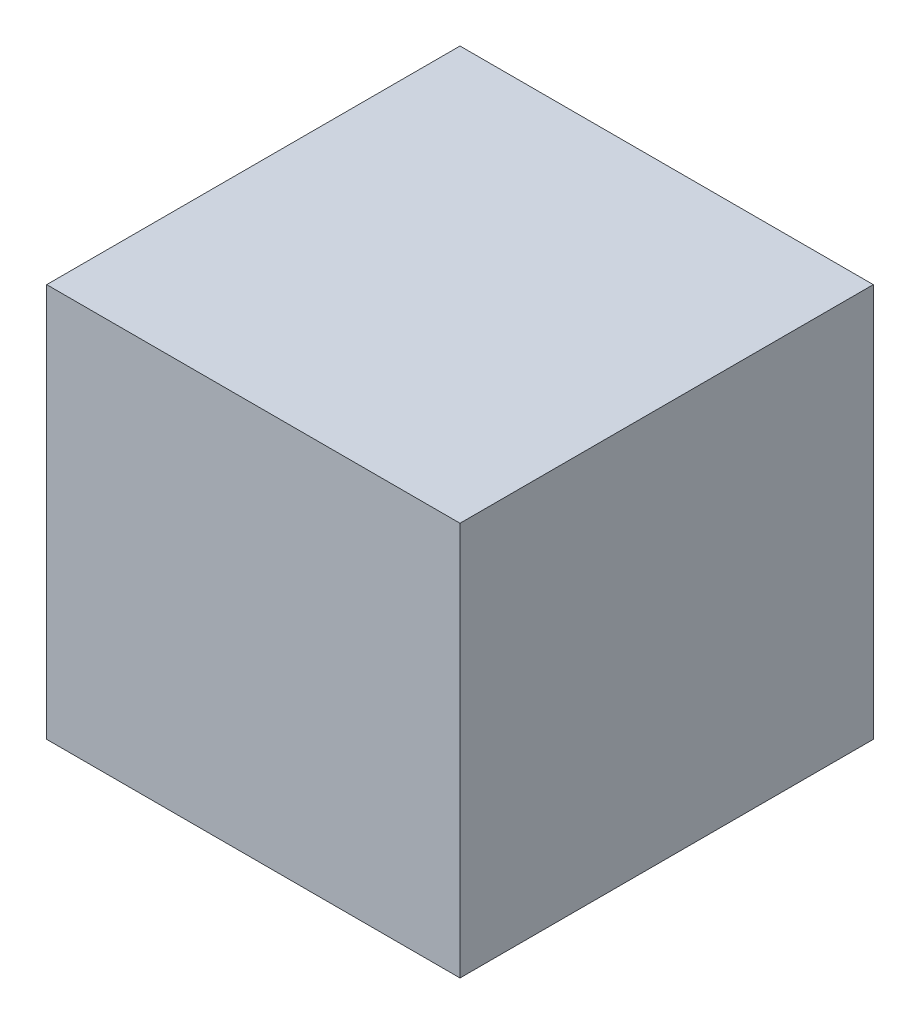
from build123d import *

# Parameters (mm, degrees)
SKETCH2_W           = 42.24
SKETCH2_H           = 42.24
BOSS_EXTRUDE1_DEPTH = 40.25


with BuildPart() as part:
    # Sketch2 → Boss-Extrude1 (new body)
    with BuildSketch(Plane(origin=(0, 0, 0), x_dir=(1, 0, 0), z_dir=(0, 1, 0))):
        with Locations((21.12, 21.12)):
            Rectangle(SKETCH2_W, SKETCH2_H)
    extrude(amount=BOSS_EXTRUDE1_DEPTH)


solid = part.part
